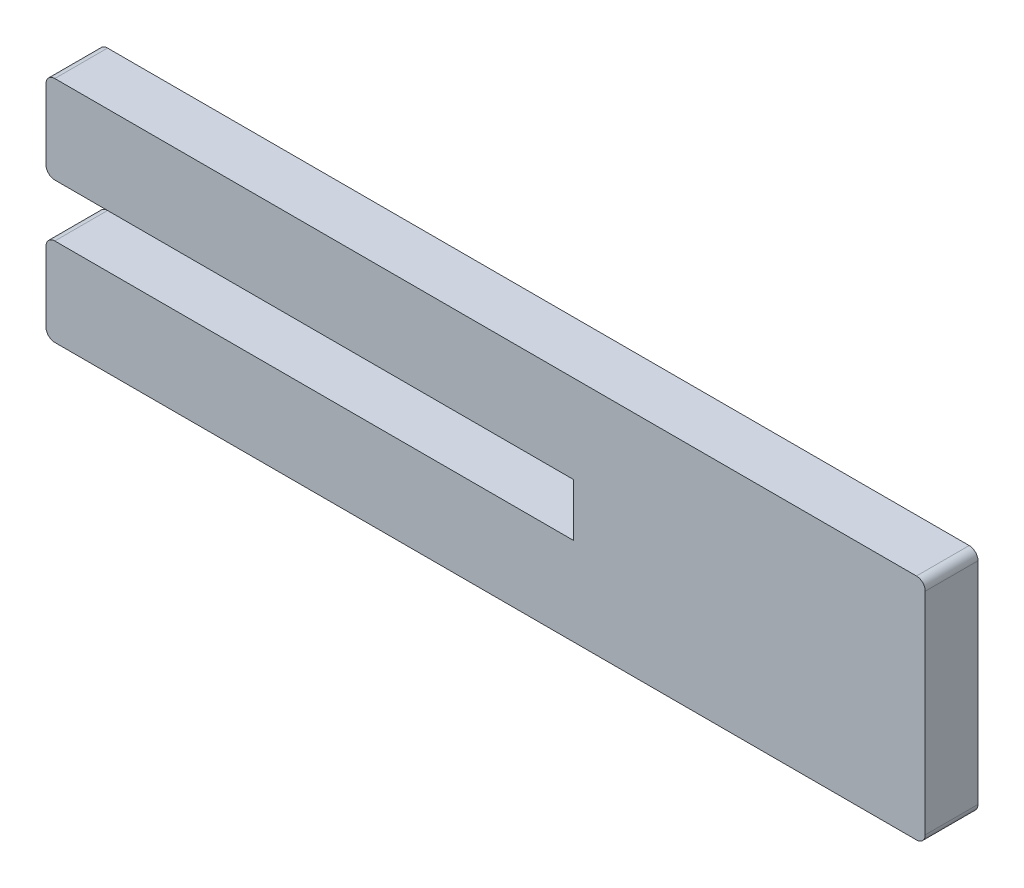
from build123d import *

# Parameters (mm, degrees)
SALIENTE_EXTRUIR1_DEPTH = 3


with BuildPart() as part:
    # Croquis1 → Saliente-Extruir1 (new body)
    with BuildSketch(Plane.XY):
        with BuildLine():
            Line((-29.5, 1.5), (0, 1.5))
            Line((0, 1.5), (0, -1.5))
            Line((0, -1.5), (-29.5, -1.5))
            ThreePointArc((-29.5, -1.5), (-29.853553391, -1.646446609), (-30, -2))
            Line((-30, -2), (-30, -6))
            ThreePointArc((-30, -6), (-29.853553391, -6.353553391), (-29.5, -6.5))
            Line((-29.5, -6.5), (19.5, -6.5))
            ThreePointArc((19.5, -6.5), (19.853553391, -6.353553391), (20, -6))
            Line((20, -6), (20, 0))
            Line((20, 0), (20, 6))
            ThreePointArc((20, 6), (19.853553391, 6.353553391), (19.5, 6.5))
            Line((19.5, 6.5), (-29.5, 6.5))
            ThreePointArc((-29.5, 6.5), (-29.853553391, 6.353553391), (-30, 6))
            Line((-30, 6), (-30, 2))
            ThreePointArc((-30, 2), (-29.853553391, 1.646446609), (-29.5, 1.5))
        make_face()
    extrude(amount=SALIENTE_EXTRUIR1_DEPTH)


solid = part.part
